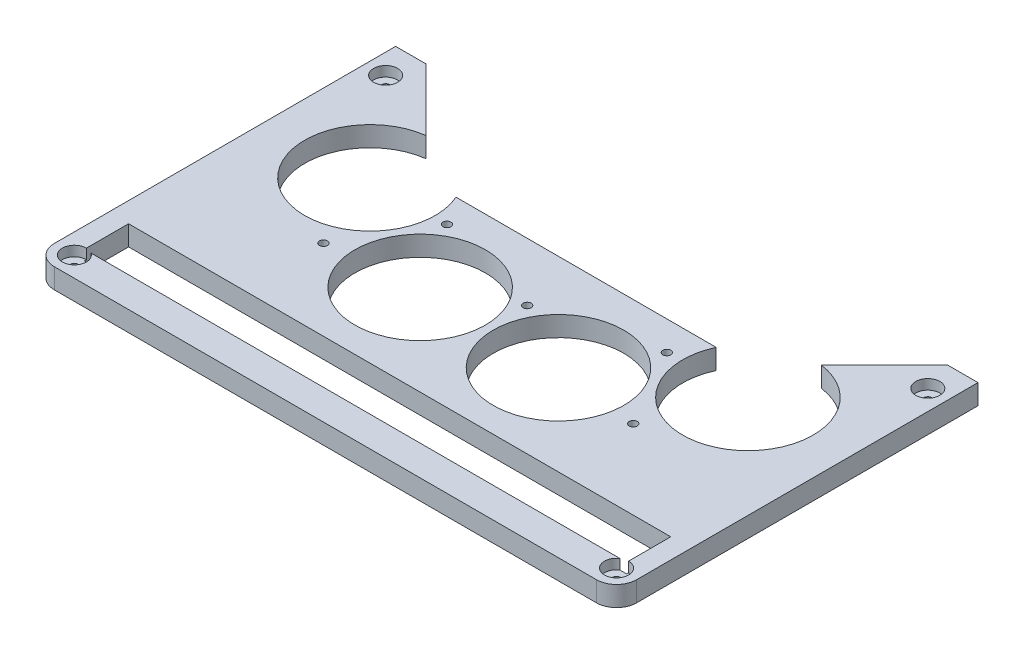
from build123d import *

# Parameters (mm, degrees)
BOSS_EXTRU_1_DEPTH      = 10
ESQUISSE3_R             = 2
ENL_V_MAT_EXTRU_1_DEPTH = 10
CONG_1_R                = 10
ESQUISSE4_R             = 32.5
ENL_V_MAT_EXTRU_2_DEPTH = 10
ESQUISSE5_R             = 2
ENL_V_MAT_EXTRU_3_DEPTH = 10
ESQUISSE6_W             = 270
ESQUISSE6_H             = 22
ENL_V_MAT_EXTRU_4_DEPTH = 10
ESQUISSE7_R             = 2
ENL_V_MAT_EXTRU_5_DEPTH = 10
ESQUISSE10_R            = 6
ENL_V_MAT_EXTRU_6_DEPTH = 5


with BuildPart() as part:
    # Esquisse2 → Boss.-Extru.1 (new body)
    with BuildSketch(Plane(origin=(0, 0, 0), x_dir=(1, 0, 0), z_dir=(0, 1, 0))):
        Polygon((0, 0), (290, 0), (290, 180), (275, 180), (225, 130), (65, 130), (15, 180), (0, 180), align=None)
    extrude(amount=BOSS_EXTRU_1_DEPTH)

    # Esquisse3 → Enlèv. mat.-Extru.1 (cut)
    with BuildSketch(Plane(origin=(0, 10, 0), x_dir=(1, 0, 0), z_dir=(0, 1, 0))):
        with Locations((10, 10)):
            Circle(ESQUISSE3_R)
        with Locations((280, 10)):
            Circle(ESQUISSE3_R)
    extrude(amount=-ENL_V_MAT_EXTRU_1_DEPTH, mode=Mode.SUBTRACT)

    # Congé1
    cong_1_edges = [part.edges().sort_by_distance(p)[0] for p in [
        (290, 5, 0),
        (0, 5, 0),
    ]]
    fillet(cong_1_edges, radius=CONG_1_R)

    # Esquisse4 → Enlèv. mat.-Extru.2 (cut)
    with BuildSketch(Plane.XZ):
        with Locations((239.106279441, -116.309672248)):
            Circle(ESQUISSE4_R)
        with Locations((179.153264776, -81.942630954)):
            Circle(ESQUISSE4_R)
        with Locations((110.048910395, -82.156407472)):
            Circle(ESQUISSE4_R)
        with Locations((50.309672248, -116.893720559)):
            Circle(ESQUISSE4_R)
    extrude(amount=-ENL_V_MAT_EXTRU_2_DEPTH, mode=Mode.SUBTRACT)

    # Esquisse5 → Enlèv. mat.-Extru.3 (cut)
    with BuildSketch(Plane(origin=(0, 0, 0), x_dir=(-1, 0, 0), z_dir=(0, -1, 0))):
        with Locations((-144.50570114, 101.001110603)):
            Circle(ESQUISSE5_R)
        with Locations((-199.571369329, 115.491017964)):
            Circle(ESQUISSE5_R)
        with Locations((-221.896020418, 76.419161677)):
            Circle(ESQUISSE5_R)
        with Locations((-66.897585359, 77.115673706)):
            Circle(ESQUISSE5_R)
        with Locations((-89.572479932, 115.985316824)):
            Circle(ESQUISSE5_R)
    extrude(amount=-ENL_V_MAT_EXTRU_3_DEPTH, mode=Mode.SUBTRACT)

    # Esquisse6 → Enlèv. mat.-Extru.4 (cut)
    with BuildSketch(Plane(origin=(0, 10, 0), x_dir=(1, 0, 0), z_dir=(0, 1, 0))):
        with Locations((145, 26)):
            Rectangle(ESQUISSE6_W, ESQUISSE6_H)
    extrude(amount=-ENL_V_MAT_EXTRU_4_DEPTH, mode=Mode.SUBTRACT)

    # Esquisse7 → Enlèv. mat.-Extru.5 (cut)
    with BuildSketch(Plane(origin=(0, 10, 0), x_dir=(1, 0, 0), z_dir=(0, 1, 0))):
        with Locations((10, 165)):
            Circle(ESQUISSE7_R)
        with Locations((280, 165)):
            Circle(ESQUISSE7_R)
    extrude(amount=-ENL_V_MAT_EXTRU_5_DEPTH, mode=Mode.SUBTRACT)

    # Esquisse10 → Enlèv. mat.-Extru.6 (cut)
    with BuildSketch(Plane(origin=(0, 10, 0), x_dir=(1, 0, 0), z_dir=(0, 1, 0))):
        with Locations((10, 165)):
            Circle(ESQUISSE10_R)
        with Locations((280, 165)):
            Circle(ESQUISSE10_R)
        with Locations((280, 10)):
            Circle(ESQUISSE10_R)
        with Locations((10, 10)):
            Circle(ESQUISSE10_R)
    extrude(amount=-ENL_V_MAT_EXTRU_6_DEPTH, mode=Mode.SUBTRACT)


solid = part.part
